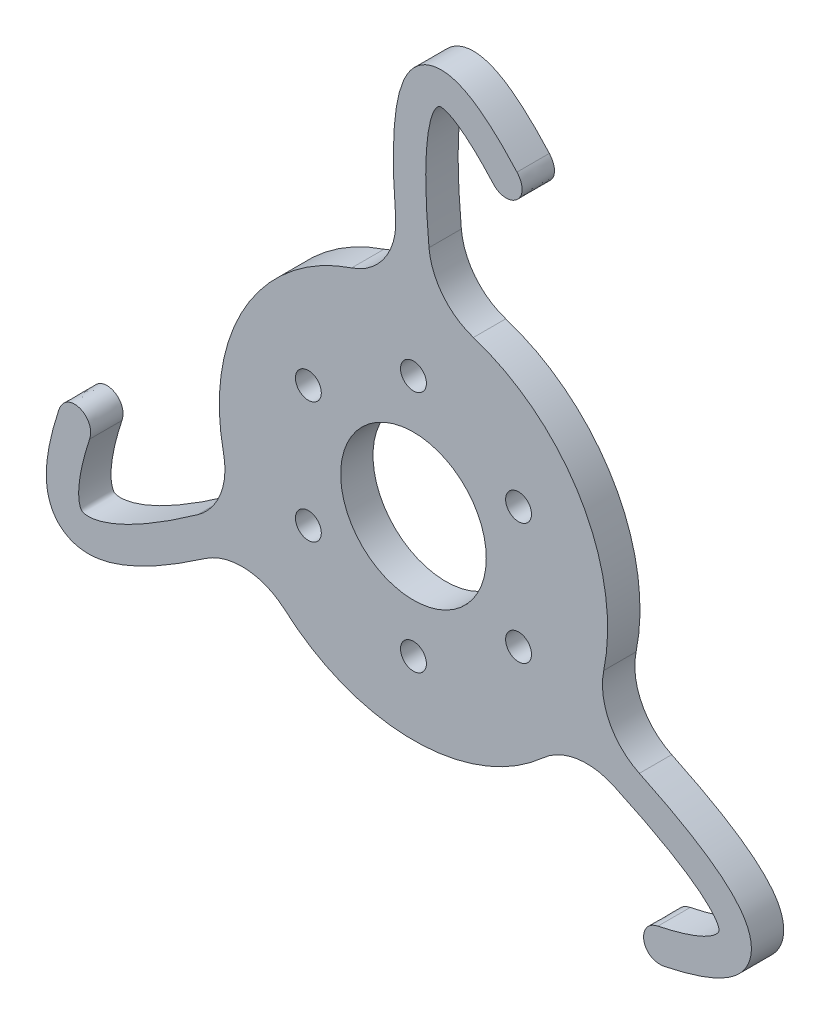
from build123d import *

# Parameters (mm, degrees)
SKETCH1_R                = 38.1
BOSS_EXTRUDE1_DEPTH      = 6.35
CUT_EXTRUDE1_REACH       = 8.35
SKETCH2_R                = 14.2875
CUT_EXTRUDE2_REACH       = 8.35
SKETCH3_R                = 2.54
BOSS_EXTRUDE2_DEPTH      = 6.35
FILLET1_R                = 12.7
CIRPATTERN1_COUNT        = 3
FILLET1_OF_CIRPATTERN1_R = 12.7


with BuildPart() as part:
    # Sketch1 → Boss-Extrude1 (new body)
    with BuildSketch(Plane.XY):
        Circle(SKETCH1_R)
    extrude(amount=BOSS_EXTRUDE1_DEPTH)

    # Sketch2 → Cut-Extrude1 (cut, up to next)
    with BuildSketch(Plane.XY.offset(6.35), mode=Mode.PRIVATE) as cut_extrude1_sk1:
        Circle(SKETCH2_R)
    cut_extrude1_tool1 = extrude(cut_extrude1_sk1.sketch, amount=-CUT_EXTRUDE1_REACH, mode=Mode.PRIVATE) & part.part
    add(cut_extrude1_tool1.solids().sort_by_distance((0, 0, 6.35))[0], mode=Mode.SUBTRACT)

    # Sketch3 → Cut-Extrude2 (cut, up to next)
    with BuildSketch(Plane.XY.offset(6.35), mode=Mode.PRIVATE) as cut_extrude2_sk1:
        with Locations((0, 23.8125)):
            Circle(SKETCH3_R)
    cut_extrude2_tool1 = extrude(cut_extrude2_sk1.sketch, amount=-CUT_EXTRUDE2_REACH, mode=Mode.PRIVATE) & part.part
    add(cut_extrude2_tool1.solids().sort_by_distance((0, 23.8125, 6.35))[0], mode=Mode.SUBTRACT)
    # Sketch3 → Cut-Extrude2 (cut, up to next)
    with BuildSketch(Plane.XY.offset(6.35), mode=Mode.PRIVATE) as cut_extrude2_sk2:
        with Locations((20.622229928, 11.90625)):
            Circle(SKETCH3_R)
    cut_extrude2_tool2 = extrude(cut_extrude2_sk2.sketch, amount=-CUT_EXTRUDE2_REACH, mode=Mode.PRIVATE) & part.part
    add(cut_extrude2_tool2.solids().sort_by_distance((20.62223, 11.90625, 6.35))[0], mode=Mode.SUBTRACT)
    # Sketch3 → Cut-Extrude2 (cut, up to next)
    with BuildSketch(Plane.XY.offset(6.35), mode=Mode.PRIVATE) as cut_extrude2_sk3:
        with Locations((20.622229928, -11.90625)):
            Circle(SKETCH3_R)
    cut_extrude2_tool3 = extrude(cut_extrude2_sk3.sketch, amount=-CUT_EXTRUDE2_REACH, mode=Mode.PRIVATE) & part.part
    add(cut_extrude2_tool3.solids().sort_by_distance((20.62223, -11.90625, 6.35))[0], mode=Mode.SUBTRACT)
    # Sketch3 → Cut-Extrude2 (cut, up to next)
    with BuildSketch(Plane.XY.offset(6.35), mode=Mode.PRIVATE) as cut_extrude2_sk4:
        with Locations((0, -23.8125)):
            Circle(SKETCH3_R)
    cut_extrude2_tool4 = extrude(cut_extrude2_sk4.sketch, amount=-CUT_EXTRUDE2_REACH, mode=Mode.PRIVATE) & part.part
    add(cut_extrude2_tool4.solids().sort_by_distance((0, -23.8125, 6.35))[0], mode=Mode.SUBTRACT)
    # Sketch3 → Cut-Extrude2 (cut, up to next)
    with BuildSketch(Plane.XY.offset(6.35), mode=Mode.PRIVATE) as cut_extrude2_sk5:
        with Locations((-20.622229928, -11.90625)):
            Circle(SKETCH3_R)
    cut_extrude2_tool5 = extrude(cut_extrude2_sk5.sketch, amount=-CUT_EXTRUDE2_REACH, mode=Mode.PRIVATE) & part.part
    add(cut_extrude2_tool5.solids().sort_by_distance((-20.62223, -11.90625, 6.35))[0], mode=Mode.SUBTRACT)
    # Sketch3 → Cut-Extrude2 (cut, up to next)
    with BuildSketch(Plane.XY.offset(6.35), mode=Mode.PRIVATE) as cut_extrude2_sk6:
        with Locations((-20.622229928, 11.90625)):
            Circle(SKETCH3_R)
    cut_extrude2_tool6 = extrude(cut_extrude2_sk6.sketch, amount=-CUT_EXTRUDE2_REACH, mode=Mode.PRIVATE) & part.part
    add(cut_extrude2_tool6.solids().sort_by_distance((-20.62223, 11.90625, 6.35))[0], mode=Mode.SUBTRACT)

    # Sketch4 → Boss-Extrude2 (add)
    with BuildSketch(Plane.XY.offset(6.35)):
        with BuildLine():
            ThreePointArc((-2.327008564, 38.028871021), (0.887369733, 38.089664936), (4.095429676, 37.879248353))
            add(Edge.make_bspline(
                [(4.095429676, 37.879248353), (4.04215075, 38.285530301), (3.914461772, 39.274413524), (3.655527149, 41.363229609), (3.343399159, 44.090784791), (3.031870894, 47.190777486), (2.699485181, 51.098725956), (2.439553957, 55.555831097), (2.373624604, 60.210240855), (2.547558507, 64.153436959), (2.947263754, 67.358449805), (3.538793496, 69.780770254), (4.23796343, 71.360694372), (4.846828185, 72.057975631), (5.093515528, 72.169377451), (5.427936963, 72.250865955), (6.468279952, 72.053475207), (8.129410044, 71.224579981), (9.89550448, 69.945752357), (11.491384426, 68.566755802), (12.772349127, 67.356996103), (13.908073787, 66.200602276), (14.849532917, 65.194156137), (15.341511138, 64.652157775), (15.582032526, 64.383470823)],
                knots=[0.004712861, 0.004712861, 0.004712861, 0.004712861, 0.015625, 0.03125, 0.0625, 0.09375, 0.125, 0.1875, 0.25, 0.3125, 0.375, 0.4375, 0.5, 0.5625, 0.625, 0.6875, 0.75, 0.8125, 0.875, 0.90625, 0.9375, 0.96875, 0.984375, 1, 1, 1, 1], degree=3))
            add(Edge.make_bspline(
                [(15.582032526, 64.383470823), (18.521617579, 61.109007561), (23.464623076, 64.899376671), (20.313288561, 68.618764949)],
                knots=[0, 0, 0, 0, 1, 1, 1, 1], degree=3))
            add(Edge.make_bspline(
                [(-2.327008564, 38.028871021), (-2.338323481, 38.117312543), (-2.424651885, 38.794450149), (-2.650173696, 40.613672234), (-2.970157823, 43.409606778), (-3.290931467, 46.60101215), (-3.634986625, 50.645198433), (-3.907403893, 55.304190964), (-3.979411634, 60.272414348), (-3.790336405, 64.634677195), (-3.326103754, 68.418080447), (-2.552762124, 71.667098019), (-1.386128582, 74.441443403), (0.371743014, 76.781360115), (2.992723181, 78.39008723), (6.026906515, 78.711651655), (8.856082863, 77.995044714), (11.565471339, 76.592797047), (13.858711772, 74.915012054), (15.761230939, 73.269663771), (17.22802832, 71.883316318), (18.490507138, 70.597383807), (19.521164581, 69.495459086), (20.052626041, 68.909951602), (20.313288561, 68.618764949)],
                knots=[0.013282809, 0.013282809, 0.013282809, 0.013282809, 0.015625, 0.03125, 0.0625, 0.09375, 0.125, 0.1875, 0.25, 0.3125, 0.375, 0.4375, 0.5, 0.5625, 0.625, 0.6875, 0.75, 0.8125, 0.875, 0.90625, 0.9375, 0.96875, 0.984375, 1, 1, 1, 1], degree=3))
        make_face()
    boss_extrude2 = extrude(amount=-BOSS_EXTRUDE2_DEPTH)

    # Fillet1
    fillet1_edges = [part.edges().sort_by_distance(p)[0] for p in [
        (4.095429676, 37.879248353, 3.175),
        (-2.327008564, 38.028871021, 3.175),
    ]]
    fillet(fillet1_edges, radius=FILLET1_R)

    # CirPattern1: Boss-Extrude2 ×3 about axis
    cirpattern1_axis = Axis((0, 0, -43.945289339), (0, 0, 1))
    for i in range(1, CIRPATTERN1_COUNT):
        add(boss_extrude2.rotate(cirpattern1_axis, i * 360 / CIRPATTERN1_COUNT))

    # Fillet1 of CirPattern1
    fillet1_of_cirpattern1_edges = [part.edges().sort_by_distance(p)[0] for p in [
        (-34.852106188, -15.392878037, 3.175),
        (-31.770464099, -21.029684042, 3.175),
        (30.756676512, -22.486370315, 3.175),
        (34.097472664, -16.999186979, 3.175),
    ]]
    fillet(fillet1_of_cirpattern1_edges, radius=FILLET1_OF_CIRPATTERN1_R)


solid = part.part
